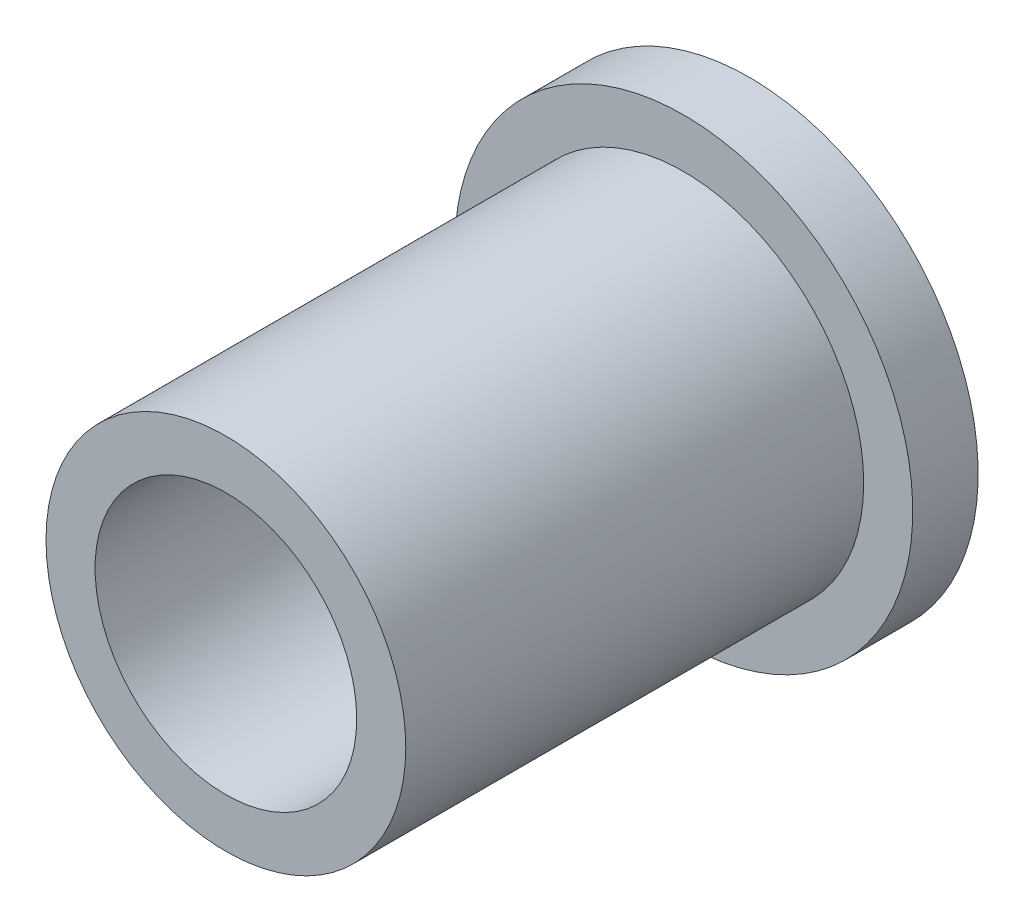
from build123d import *

# Parameters (mm, degrees)
ESQUISSE1_R        = 2.75
ESQUISSE1_R_2      = 2
BOSS_EXTRU_1_DEPTH = 8
ESQUISSE2_R        = 3.5
ESQUISSE2_R_2      = 2.75
BOSS_EXTRU_2_DEPTH = 1


with BuildPart() as part:
    # Esquisse1 → Boss.-Extru.1 (new body)
    with BuildSketch(Plane.XY):
        Circle(ESQUISSE1_R)
        Circle(ESQUISSE1_R_2, mode=Mode.SUBTRACT)
    extrude(amount=BOSS_EXTRU_1_DEPTH)

    # Esquisse2 → Boss.-Extru.2 (add)
    with BuildSketch(Plane(origin=(0, 0, 0), x_dir=(-1, 0, 0), z_dir=(0, 0, -1))):
        Circle(ESQUISSE2_R)
        Circle(ESQUISSE2_R_2, mode=Mode.SUBTRACT)
    extrude(amount=-BOSS_EXTRU_2_DEPTH)


solid = part.part
